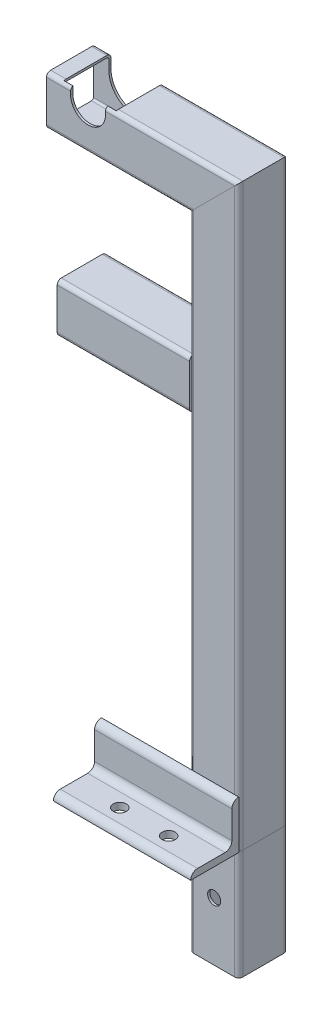
from build123d import *

# Parameters (mm, degrees)
STRUCTURAL_MEMBERMAIN_DEPTH                   = 1
STRUCTURAL_MEMBERMAIN_DEPTH_BACK              = 80
STRUCTURAL_MEMBERMAIN_2_DEPTH                 = 431.314422766
STRUCTURAL_MEMBERMAIN_3_DEPTH                 = 148.414422766
STRUCTURAL_MEMBERMAIN_4_DEPTH                 = 115.3
CUT_EXTRUDETOPRAILGUIDE_DEPTH                 = 515.966225986
CUT_EXTRUDETOPRAILGUIDE_DEPTH_BACK            = 515.966225986
STRUCTURAL_MEMBERANGLE_DEPTH                  = 100
SKETCH15_R                                    = 4.7625
CUT_EXTRUDEMOUNTINGHOLES_DEPTH                = 518.366614603
CUT_EXTRUDEENLARGERAILGUIDE_DEPTH             = 518.366614603
CUT_EXTRUDEENLARGERAILGUIDE_DIRECTION_2_REACH = 519.367
SKETCH17_R                                    = 4.7625
CUT_EXTRUDE1_DEPTH                            = 516.898676007


with BuildPart() as part:
    # Sketch11 → Structural MemberMain (new, two sides)
    with BuildSketch(Plane(origin=(276.8375, 0, 0), x_dir=(-1, 0, 0), z_dir=(0, 1, 0))) as structural_membermain_sk:
        with BuildLine():
            Line((-14.9, 17.9), (14.9, 17.9))
            ThreePointArc((14.9, 17.9), (17.021320344, 17.021320344), (17.9, 14.9))
            Line((17.9, 14.9), (17.9, -14.9))
            ThreePointArc((17.9, -14.9), (17.021320344, -17.021320344), (14.9, -17.9))
            Line((14.9, -17.9), (-14.9, -17.9))
            ThreePointArc((-14.9, -17.9), (-17.021320344, -17.021320344), (-17.9, -14.9))
            Line((-17.9, -14.9), (-17.9, 14.9))
            ThreePointArc((-17.9, 14.9), (-17.021320344, 17.021320344), (-14.9, 17.9))
        make_face()
        with BuildLine():
            Line((-14.9, 16.3), (14.9, 16.3))
            ThreePointArc((14.9, 16.3), (15.889949494, 15.889949494), (16.3, 14.9))
            Line((16.3, 14.9), (16.3, -14.9))
            ThreePointArc((16.3, -14.9), (15.889949494, -15.889949494), (14.9, -16.3))
            Line((14.9, -16.3), (-14.9, -16.3))
            ThreePointArc((-14.9, -16.3), (-15.889949494, -15.889949494), (-16.3, -14.9))
            Line((-16.3, -14.9), (-16.3, 14.9))
            ThreePointArc((-16.3, 14.9), (-15.889949494, 15.889949494), (-14.9, 16.3))
        make_face(mode=Mode.SUBTRACT)
    extrude(amount=STRUCTURAL_MEMBERMAIN_DEPTH)
    extrude(structural_membermain_sk.sketch, amount=-STRUCTURAL_MEMBERMAIN_DEPTH_BACK)

    # Structural MemberMain mitre 1
    split(bisect_by=Plane(origin=(276.8375, 0, 0), x_dir=(1, 0, 0), z_dir=(0, -1, 0)), keep=Keep.TOP)

    # Sketch17 → Cut-Extrude1 (cut, through all)
    with BuildSketch(Plane.XY.offset(17.9)):
        with Locations((276.8375, -37.5)):
            Circle(SKETCH17_R)
    extrude(amount=-CUT_EXTRUDE1_DEPTH, mode=Mode.SUBTRACT)


with BuildPart() as body_2:
    # Sketch11 on segment 2 (carried to segment 2) → Structural MemberMain 2 (new body)
    with BuildSketch(Plane(origin=(276.8375, -1, 0), x_dir=(-1, 0, 0), z_dir=(0, 1, 0))):
        with BuildLine():
            Line((-14.9, 17.9), (14.9, 17.9))
            ThreePointArc((14.9, 17.9), (17.021320344, 17.021320344), (17.9, 14.9))
            Line((17.9, 14.9), (17.9, -14.9))
            ThreePointArc((17.9, -14.9), (17.021320344, -17.021320344), (14.9, -17.9))
            Line((14.9, -17.9), (-14.9, -17.9))
            ThreePointArc((-14.9, -17.9), (-17.021320344, -17.021320344), (-17.9, -14.9))
            Line((-17.9, -14.9), (-17.9, 14.9))
            ThreePointArc((-17.9, 14.9), (-17.021320344, 17.021320344), (-14.9, 17.9))
        make_face()
        with BuildLine():
            Line((-14.9, 16.3), (14.9, 16.3))
            ThreePointArc((14.9, 16.3), (15.889949494, 15.889949494), (16.3, 14.9))
            Line((16.3, 14.9), (16.3, -14.9))
            ThreePointArc((16.3, -14.9), (15.889949494, -15.889949494), (14.9, -16.3))
            Line((14.9, -16.3), (-14.9, -16.3))
            ThreePointArc((-14.9, -16.3), (-15.889949494, -15.889949494), (-16.3, -14.9))
            Line((-16.3, -14.9), (-16.3, 14.9))
            ThreePointArc((-16.3, 14.9), (-15.889949494, 15.889949494), (-14.9, 16.3))
        make_face(mode=Mode.SUBTRACT)
    extrude(amount=STRUCTURAL_MEMBERMAIN_2_DEPTH)

    # Structural MemberMain 2 mitre 1
    split(bisect_by=Plane(origin=(276.8375, 0, 0), x_dir=(-1, 0, 0), z_dir=(0, 1, 0)), keep=Keep.TOP)

    # Structural MemberMain 2 mitre 2
    split(bisect_by=Plane(origin=(276.8375, 404, 0), x_dir=(0.707106781, 0.707106781, 0), z_dir=(0.707106781, -0.707106781, 0)), keep=Keep.TOP)


with BuildPart() as body_3:
    # Sketch11 on segment 3 (carried to segment 3) → Structural MemberMain 3 (new body)
    with BuildSketch(Plane(origin=(303.151922766, 404, 0), x_dir=(0, -1, 0), z_dir=(-1, 0, 0))):
        with BuildLine():
            Line((-14.9, 17.9), (14.9, 17.9))
            ThreePointArc((14.9, 17.9), (17.021320344, 17.021320344), (17.9, 14.9))
            Line((17.9, 14.9), (17.9, -14.9))
            ThreePointArc((17.9, -14.9), (17.021320344, -17.021320344), (14.9, -17.9))
            Line((14.9, -17.9), (-14.9, -17.9))
            ThreePointArc((-14.9, -17.9), (-17.021320344, -17.021320344), (-17.9, -14.9))
            Line((-17.9, -14.9), (-17.9, 14.9))
            ThreePointArc((-17.9, 14.9), (-17.021320344, 17.021320344), (-14.9, 17.9))
        make_face()
        with BuildLine():
            Line((-14.9, 16.3), (14.9, 16.3))
            ThreePointArc((14.9, 16.3), (15.889949494, 15.889949494), (16.3, 14.9))
            Line((16.3, 14.9), (16.3, -14.9))
            ThreePointArc((16.3, -14.9), (15.889949494, -15.889949494), (14.9, -16.3))
            Line((14.9, -16.3), (-14.9, -16.3))
            ThreePointArc((-14.9, -16.3), (-15.889949494, -15.889949494), (-16.3, -14.9))
            Line((-16.3, -14.9), (-16.3, 14.9))
            ThreePointArc((-16.3, 14.9), (-15.889949494, 15.889949494), (-14.9, 16.3))
        make_face(mode=Mode.SUBTRACT)
    extrude(amount=STRUCTURAL_MEMBERMAIN_3_DEPTH)

    # Structural MemberMain 3 mitre 1
    split(bisect_by=Plane(origin=(276.8375, 404, 0), x_dir=(-0.707106781, -0.707106781, 0), z_dir=(-0.707106781, 0.707106781, 0)), keep=Keep.TOP)

    # Sketch12 → Cut-ExtrudeTopRailGuide (cut, two sides)
    with BuildSketch(Plane.XY) as cut_extrudetoprailguide_sk:
        with BuildLine():
            Line((172.3, 416.7), (172.3, 427.1))
            ThreePointArc((172.3, 427.1), (185, 439.8), (197.7, 427.1))
            Line((197.7, 427.1), (197.7, 416.7))
            ThreePointArc((197.7, 416.7), (185, 404), (172.3, 416.7))
        make_face()
    extrude(amount=CUT_EXTRUDETOPRAILGUIDE_DEPTH, mode=Mode.SUBTRACT)
    extrude(cut_extrudetoprailguide_sk.sketch, amount=-CUT_EXTRUDETOPRAILGUIDE_DEPTH_BACK, mode=Mode.SUBTRACT)

    # Sketch16 → Cut-ExtrudeEnlargeRailGuide (cut)
    with BuildSketch(Plane.XY):
        with BuildLine():
            Line((204.1, 431.9), (204.1, 411.9))
            ThreePointArc((204.1, 411.9), (185, 392.8), (165.9, 411.9))
            Line((165.9, 411.9), (165.9, 431.9))
            ThreePointArc((165.9, 431.9), (185, 451), (204.1, 431.9))
        make_face()
    extrude(amount=-CUT_EXTRUDEENLARGERAILGUIDE_DEPTH, mode=Mode.SUBTRACT)

    # Cut-ExtrudeEnlargeRailGuide direction 2: up to this face of the body (flat: up to its plane)
    cut_extrudeenlargerailguide_direction_2_end = Plane(body_3.part.faces().sort_by_distance((218.978271579, 403.874495333, 16.3))[0])
    # Sketch16 → Cut-ExtrudeEnlargeRailGuide direction 2 (cut, up to the picked face)
    with BuildSketch(Plane.XY, mode=Mode.PRIVATE) as cut_extrudeenlargerailguide_direction_2_sk1:
        with BuildLine():
            Line((204.1, 431.9), (204.1, 411.9))
            ThreePointArc((204.1, 411.9), (185, 392.8), (165.9, 411.9))
            Line((165.9, 411.9), (165.9, 431.9))
            ThreePointArc((165.9, 431.9), (185, 451), (204.1, 431.9))
        make_face()
    cut_extrudeenlargerailguide_direction_2_tool1 = split(extrude(cut_extrudeenlargerailguide_direction_2_sk1.sketch, amount=CUT_EXTRUDEENLARGERAILGUIDE_DIRECTION_2_REACH, mode=Mode.PRIVATE), bisect_by=cut_extrudeenlargerailguide_direction_2_end, keep=Keep.BOTH, mode=Mode.PRIVATE)
    add(cut_extrudeenlargerailguide_direction_2_tool1.solids().sort_by(Axis((185, 421.9, 0), (0, 0, 1)))[0], mode=Mode.SUBTRACT)


with BuildPart() as body_4:
    # Sketch11 on segment 4 (carried to segment 4) → Structural MemberMain 4 (new body)
    with BuildSketch(Plane(origin=(162.5375, 276.9, 0), x_dir=(0, 1, 0), z_dir=(1, 0, 0))):
        with BuildLine():
            Line((-14.9, 17.9), (14.9, 17.9))
            ThreePointArc((14.9, 17.9), (17.021320344, 17.021320344), (17.9, 14.9))
            Line((17.9, 14.9), (17.9, -14.9))
            ThreePointArc((17.9, -14.9), (17.021320344, -17.021320344), (14.9, -17.9))
            Line((14.9, -17.9), (-14.9, -17.9))
            ThreePointArc((-14.9, -17.9), (-17.021320344, -17.021320344), (-17.9, -14.9))
            Line((-17.9, -14.9), (-17.9, 14.9))
            ThreePointArc((-17.9, 14.9), (-17.021320344, 17.021320344), (-14.9, 17.9))
        make_face()
        with BuildLine():
            Line((-14.9, 16.3), (14.9, 16.3))
            ThreePointArc((14.9, 16.3), (15.889949494, 15.889949494), (16.3, 14.9))
            Line((16.3, 14.9), (16.3, -14.9))
            ThreePointArc((16.3, -14.9), (15.889949494, -15.889949494), (14.9, -16.3))
            Line((14.9, -16.3), (-14.9, -16.3))
            ThreePointArc((-14.9, -16.3), (-15.889949494, -15.889949494), (-16.3, -14.9))
            Line((-16.3, -14.9), (-16.3, 14.9))
            ThreePointArc((-16.3, 14.9), (-15.889949494, 15.889949494), (-14.9, 16.3))
        make_face(mode=Mode.SUBTRACT)
    extrude(amount=STRUCTURAL_MEMBERMAIN_4_DEPTH)

    # Structural MemberMain 4 mitre 1
    split(bisect_by=Plane(origin=(258.9375, 276.9, 0), x_dir=(0, -1, 0), z_dir=(-1, 0, 0)), keep=Keep.TOP)


with BuildPart() as body_5:
    # Sketch14 → Structural MemberAngle (new body)
    with BuildSketch(Plane(origin=(194.7375, 0, 17.9), x_dir=(0, 1, 0), z_dir=(1, 0, 0))):
        with BuildLine():
            Line((0, 0), (0, 35))
            ThreePointArc((0, 35), (3.535533906, 33.535533906), (5, 30))
            Line((5, 30), (5, 10))
            ThreePointArc((5, 10), (6.464466094, 6.464466094), (10, 5))
            Line((10, 5), (30, 5))
            ThreePointArc((30, 5), (33.535533906, 3.535533906), (35, 0))
            Line((35, 0), (0, 0))
        make_face()
    extrude(amount=STRUCTURAL_MEMBERANGLE_DEPTH)

    # Sketch15 → Cut-ExtrudeMountingHoles (cut, through all)
    with BuildSketch(Plane(origin=(0, 0, 0), x_dir=(1, 0, 0), z_dir=(0, 1, 0))):
        with Locations(Location((228.1, -37.9, 0), (0, 0, 90))):
            Circle(SKETCH15_R)
        with Locations(Location((263.7, -37.9, 0), (0, 0, 90))):
            Circle(SKETCH15_R)
    extrude(amount=CUT_EXTRUDEMOUNTINGHOLES_DEPTH, mode=Mode.SUBTRACT)


solid = Compound([part.part, body_2.part, body_3.part, body_4.part, body_5.part])
